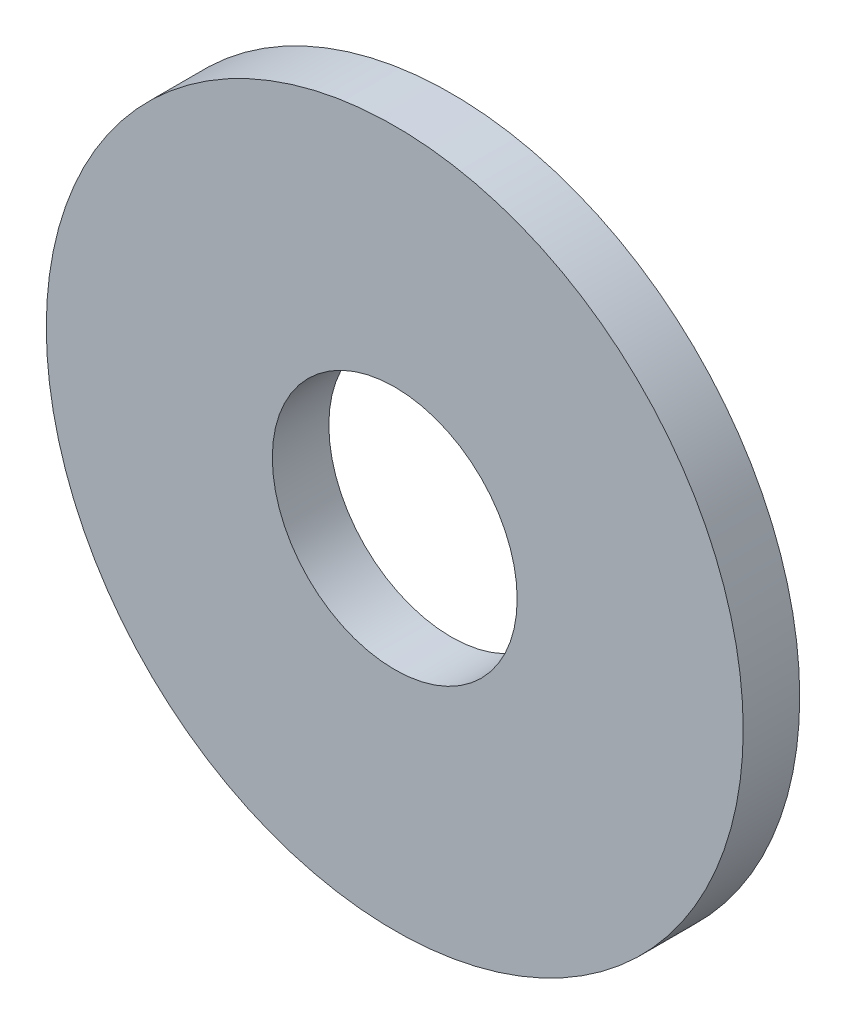
from build123d import *

# Parameters (mm, degrees)
SKETCH_243_R    = 18.5
SKETCH_243_R_2  = 6.5
EXTRUDE_1_DEPTH = 3


with BuildPart() as part:
    # Sketch 243 → 拉伸1 (new body)
    with BuildSketch(Plane.XY):
        Circle(SKETCH_243_R)
        Circle(SKETCH_243_R_2, mode=Mode.SUBTRACT)
    extrude(amount=EXTRUDE_1_DEPTH)


solid = part.part
